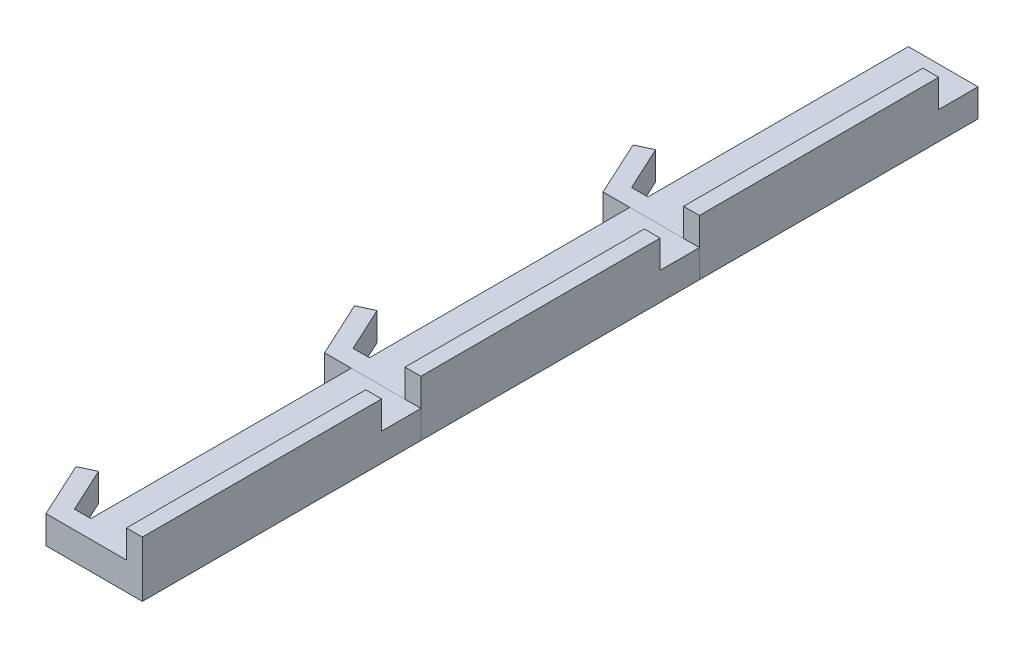
from build123d import *

# Parameters (mm, degrees)
SKIZZE1_W                       = 25
SKIZZE1_H                       = 100
AUFSATZ_LINEAR_AUSTRAGEN1_DEPTH = 5
AUFSATZ_LINEAR_AUSTRAGEN2_DEPTH = 10
SKIZZE4_W                       = 5.694336472
SKIZZE4_H                       = 85.898511164
AUFSATZ_LINEAR_AUSTRAGEN3_DEPTH = 10
LINEARES_MUSTER1_COUNT          = 3
LINEARES_MUSTER1_PITCH          = 100


with BuildPart() as part:
    # Skizze1 → Aufsatz-Linear austragen1 (new body, symmetric)
    with BuildSketch(Plane(origin=(0, 0, 0), x_dir=(1, 0, 0), z_dir=(0, 1, 0))):
        with Locations((12.5, 50)):
            Rectangle(SKIZZE1_W, SKIZZE1_H)
    extrude(amount=AUFSATZ_LINEAR_AUSTRAGEN1_DEPTH, both=True)

    # Skizze3 → Aufsatz-Linear austragen2 (add)
    with BuildSketch(Plane(origin=(0, 5, 0), x_dir=(1, 0, 0), z_dir=(0, 1, 0))):
        Polygon((0, 0), (-9.594253899, 0), (-18.845842309, 19.993203382), (-13.298383447, 22.560216038), (-5.869368316, 6.505696115), (0, 6.505696115), align=None)
    extrude(amount=-AUFSATZ_LINEAR_AUSTRAGEN2_DEPTH)

    # Skizze4 → Aufsatz-Linear austragen3 (add)
    with BuildSketch(Plane(origin=(0, 5, 0), x_dir=(1, 0, 0), z_dir=(0, 1, 0))):
        with Locations((22.152831764, 42.949255582)):
            Rectangle(SKIZZE4_W, SKIZZE4_H)
    extrude(amount=AUFSATZ_LINEAR_AUSTRAGEN3_DEPTH)


with BuildPart() as lineares_muster1_1:
    # Lineares Muster1: pattern copy
    add(part.part.moved(Location(Vector(0, 0, -1) * (1 * LINEARES_MUSTER1_PITCH))))


with BuildPart() as lineares_muster1_2:
    # Lineares Muster1: pattern copy
    add(part.part.moved(Location(Vector(0, 0, -1) * (2 * LINEARES_MUSTER1_PITCH))))


solid = Compound([part.part, lineares_muster1_1.part, lineares_muster1_2.part])
